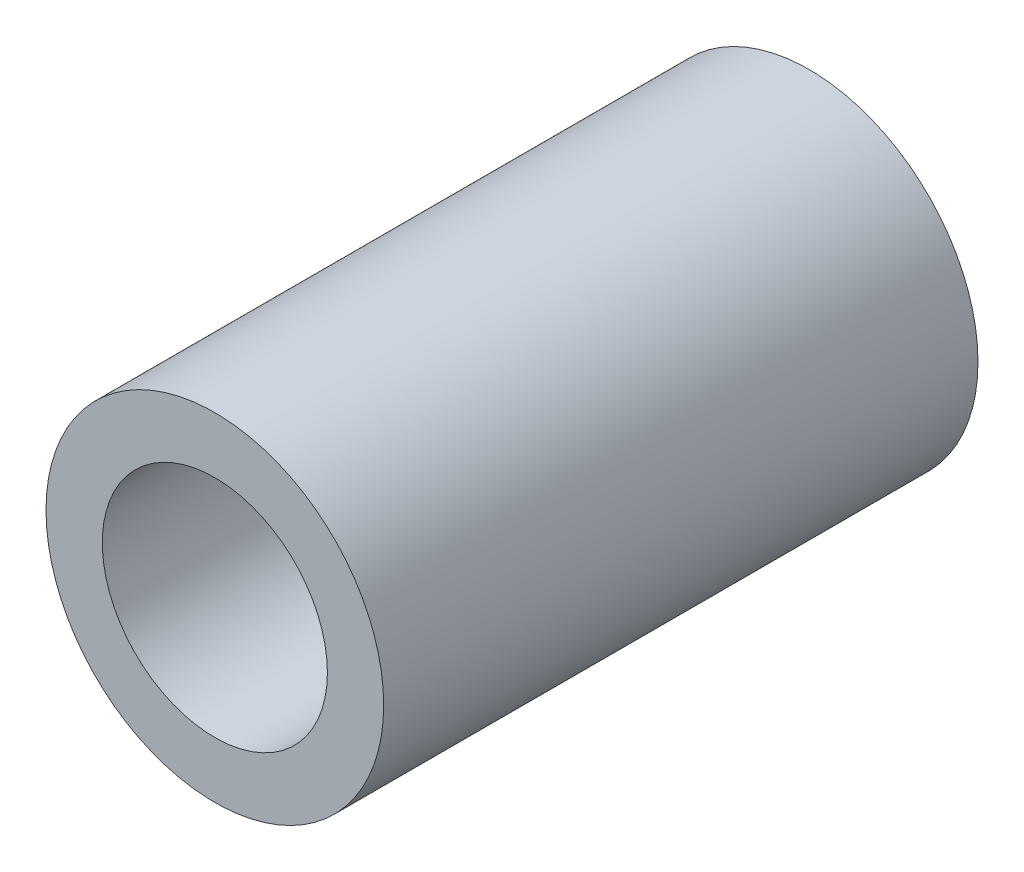
from build123d import *

# Parameters (mm, degrees)
SKETCH1_R           = 9.525
SKETCH1_R_2         = 6.35
BOSS_EXTRUDE1_DEPTH = 33.528


with BuildPart() as part:
    # Sketch1 → Boss-Extrude1 (new body)
    with BuildSketch(Plane.XY):
        Circle(SKETCH1_R)
        Circle(SKETCH1_R_2, mode=Mode.SUBTRACT)
    extrude(amount=BOSS_EXTRUDE1_DEPTH)


solid = part.part
